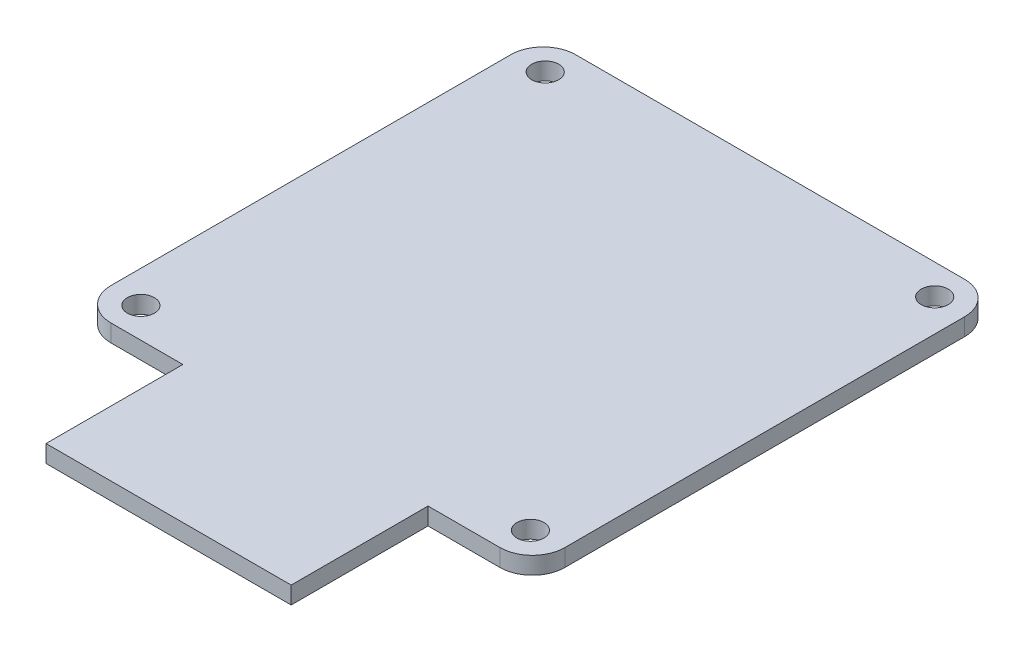
from build123d import *

# Parameters (mm, degrees)
SKETCH1_R           = 1.25
BOSS_EXTRUDE1_DEPTH = 1.6


with BuildPart() as part:
    # Sketch1 → Boss-Extrude1 (new body)
    with BuildSketch(Plane(origin=(0, 0, 0), x_dir=(1, 0, 0), z_dir=(0, 1, 0))):
        with BuildLine():
            Line((18, 21.5), (-18, 21.5))
            ThreePointArc((-18, 21.5), (-20.121320344, 20.621320344), (-21, 18.5))
            Line((-21, 18.5), (-21, -18.5))
            ThreePointArc((-21, -18.5), (-20.121320344, -20.621320344), (-18, -21.5))
            Line((-18, -21.5), (-11.343422478, -21.5))
            Line((-11.343422478, -21.5), (-11.343422478, -34.166164059))
            Line((-11.343422478, -34.166164059), (11.343422478, -34.166164059))
            Line((11.343422478, -34.166164059), (11.343422478, -21.5))
            Line((11.343422478, -21.5), (18, -21.5))
            ThreePointArc((18, -21.5), (20.121320344, -20.621320344), (21, -18.5))
            Line((21, -18.5), (21, 18.5))
            ThreePointArc((21, 18.5), (20.121320344, 20.621320344), (18, 21.5))
        make_face()
        with Locations((-18.0215, -18.707)):
            Circle(SKETCH1_R, mode=Mode.SUBTRACT)
        with Locations((18.0215, -18.707)):
            Circle(SKETCH1_R, mode=Mode.SUBTRACT)
        with Locations((-18.0215, 18.707)):
            Circle(SKETCH1_R, mode=Mode.SUBTRACT)
        with Locations((18.0215, 18.707)):
            Circle(SKETCH1_R, mode=Mode.SUBTRACT)
    extrude(amount=BOSS_EXTRUDE1_DEPTH)


solid = part.part
